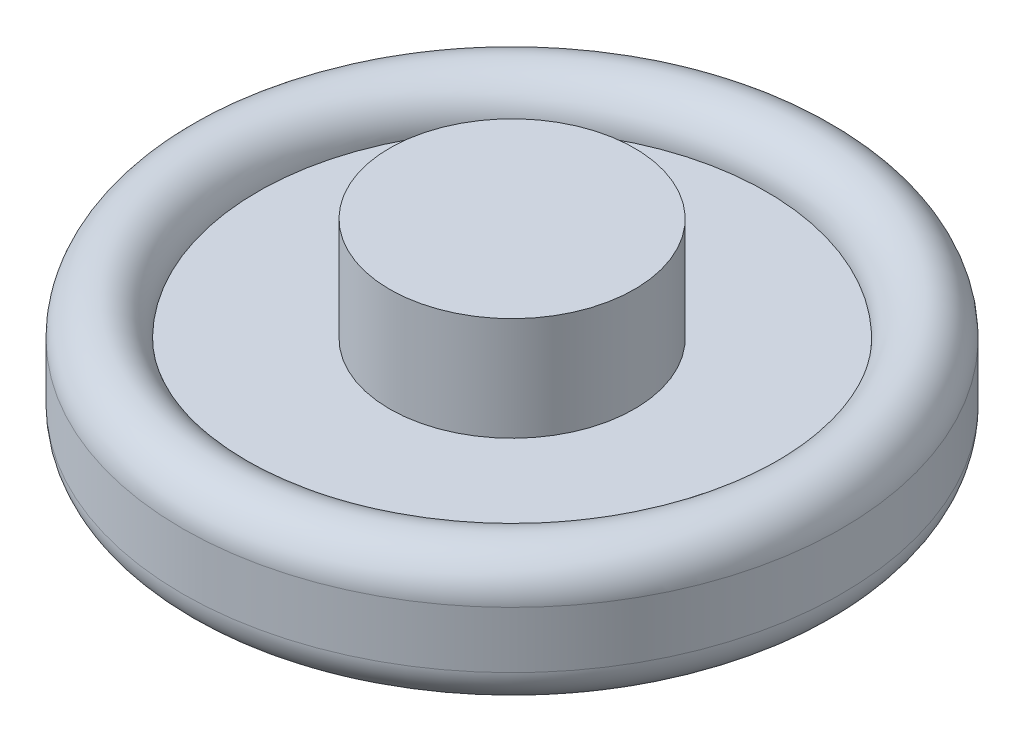
from build123d import *

# Parameters (mm, degrees)
SKETCH_1_W          = 13.5
SKETCH_1_H          = 3
SKETCH_4_R          = 6.5
EXTRUDE_1_DEPTH     = 7
CUT_EXTRUDE_1_DEPTH = 1.5
CUT_EXTRUDE_START   = 3.5
CUT_EXTRUDE_2_DEPTH = 1.5
SKETCH_6_R          = 3
CUT_EXTRUDE_3_DEPTH = 6.25


with BuildPart() as part:
    # Эскиз1 → Повернуть1 (revolve)
    with BuildSketch(Plane.XY):
        with BuildLine():
            Line((17.5, -1.5), (17.5, 1.5))
            ThreePointArc((17.5, 1.5), (15.5, 3.5), (13.5, 1.5))
            Line((13.5, 1.5), (13.5, -1.5))
            ThreePointArc((13.5, -1.5), (15.5, -3.5), (17.5, -1.5))
        make_face()
        with Locations((6.75, 0)):
            Rectangle(SKETCH_1_W, SKETCH_1_H)
    revolve(axis=Axis((0, 0, 0), (0, -1, 0)))

    # Эскиз4 → Бобышка-Вытянуть1 (add)
    with BuildSketch(Plane(origin=(0, 0, 0), x_dir=(1, 0, 0), z_dir=(0, 1, 0))):
        Circle(SKETCH_4_R)
    extrude(amount=EXTRUDE_1_DEPTH)

    # Эскиз5 → Вырез-Вытянуть1 (cut)
    with BuildSketch(Plane(origin=(0, 4.75, 0), x_dir=(-1, 0, 0), z_dir=(0, -1, 0))):
        Polygon((2.309401077, 4), (-2.309401077, 4), (-4.618802154, 0), (-2.309401077, -4), (2.309401077, -4), (4.618802154, 0), align=None)
    extrude(amount=CUT_EXTRUDE_1_DEPTH, mode=Mode.SUBTRACT)

    # Эскиз5<2> → Вырез-Вытянуть2 (cut)
    with BuildSketch(Plane(origin=(0, 4.75, 0), x_dir=(-1, 0, 0), z_dir=(0, -1, 0)).offset(CUT_EXTRUDE_START)):
        Polygon((2.309401077, 4), (-2.309401077, 4), (-4.618802154, 0), (-2.309401077, -4), (2.309401077, -4), (4.618802154, 0), align=None)
    extrude(amount=CUT_EXTRUDE_2_DEPTH, mode=Mode.SUBTRACT)

    # Эскиз6 → Вырез-Вытянуть3 (cut)
    with BuildSketch(Plane.XZ.offset(1.5)):
        Circle(SKETCH_6_R)
    extrude(amount=-CUT_EXTRUDE_3_DEPTH, mode=Mode.SUBTRACT)


solid = part.part
